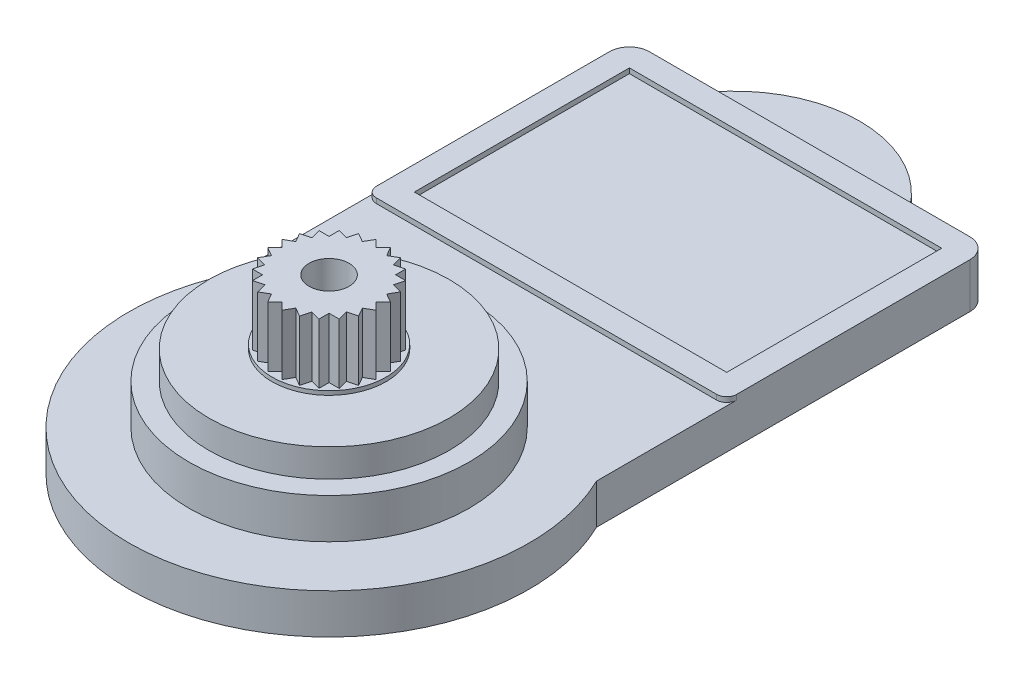
from build123d import *

# Parameters (mm, degrees)
BOSS_EXTRUDE1_DEPTH = 2
BOSS_EXTRUDE2_DEPTH = 0.25
SKETCH3_W           = 15.6
SKETCH3_H           = 10.74
CUT_EXTRUDE1_DEPTH  = 0.25
SKETCH4_R           = 7
BOSS_EXTRUDE3_DEPTH = 2
SKETCH5_R           = 6
BOSS_EXTRUDE4_DEPTH = 1.4
SKETCH6_R           = 2.85
BOSS_EXTRUDE5_DEPTH = 0.2
BOSS_EXTRUDE6_DEPTH = 3
SKETCH10_R          = 1
CUT_EXTRUDE4_DEPTH  = 3


with BuildPart() as part:
    # Sketch1 → Boss-Extrude1 (new body)
    with BuildSketch(Plane(origin=(0, 0, 0), x_dir=(1, 0, 0), z_dir=(0, 1, 0))):
        with BuildLine():
            ThreePointArc((5, 13.05), (0, 15.55), (-5, 13.05))
            Line((-5, 13.05), (-8, 13.05))
            ThreePointArc((-8, 13.05), (-8.70710678, 12.757106782), (-9, 12.050000002))
            Line((-9, 12.050000002), (-9, -6.591101056))
            ThreePointArc((-9, -6.591101056), (0, -20.95), (9, -6.591101056))
            Line((9, -6.591101056), (9, 12.05))
            ThreePointArc((9, 12.05), (8.707106781, 12.757106781), (8, 13.05))
            Line((8, 13.05), (5, 13.05))
        make_face()
    extrude(amount=BOSS_EXTRUDE1_DEPTH)

    # Sketch2 → Boss-Extrude2 (add)
    with BuildSketch(Plane(origin=(0, 2, 0), x_dir=(-1, 0, 0), z_dir=(0, 1, 0))):
        with BuildLine():
            Line((-8.000000002, -13.05), (8, -13.05))
            ThreePointArc((8, -13.05), (8.707106781, -12.757106781), (9, -12.05))
            Line((9, -12.05), (9, -0.41))
            ThreePointArc((9, -0.41), (8.853553391, -0.056446609), (8.5, 0.09))
            Line((8.5, 0.09), (-8.5, 0.09))
            ThreePointArc((-8.5, 0.09), (-8.853553391, -0.056446609), (-9, -0.41))
            Line((-9, -0.41), (-9, -12.05))
            ThreePointArc((-9, -12.05), (-8.707106782, -12.757106781), (-8.000000002, -13.05))
        make_face()
    extrude(amount=BOSS_EXTRUDE2_DEPTH)

    # Sketch3 → Cut-Extrude1 (cut)
    with BuildSketch(Plane(origin=(0, 2.25, 0), x_dir=(-1, 0, 0), z_dir=(0, 1, 0))):
        with Locations((0, -6.48)):
            Rectangle(SKETCH3_W, SKETCH3_H)
    extrude(amount=-CUT_EXTRUDE1_DEPTH, mode=Mode.SUBTRACT)

    # Sketch4 → Boss-Extrude3 (add)
    with BuildSketch(Plane(origin=(0, 2, 0), x_dir=(-1, 0, 0), z_dir=(0, 1, 0))):
        with Locations((0, 10.95)):
            Circle(SKETCH4_R)
    extrude(amount=BOSS_EXTRUDE3_DEPTH)

    # Sketch5 → Boss-Extrude4 (add)
    with BuildSketch(Plane(origin=(0, 4, 0), x_dir=(-1, 0, 0), z_dir=(0, 1, 0))):
        with Locations((0, 10.95)):
            Circle(SKETCH5_R)
    extrude(amount=BOSS_EXTRUDE4_DEPTH)

    # Sketch6 → Boss-Extrude5 (add)
    with BuildSketch(Plane(origin=(0, 5.4, 0), x_dir=(-1, 0, 0), z_dir=(0, 1, 0))):
        with Locations((0, 10.95)):
            Circle(SKETCH6_R)
    extrude(amount=BOSS_EXTRUDE5_DEPTH)

    # Sketch9 → Boss-Extrude6 (add)
    with BuildSketch(Plane(origin=(0, 5.6, 0), x_dir=(-1, 0, 0), z_dir=(0, 1, 0))):
        Polygon((-0.356289813, 8.243710187), (0, 8.6), (0.356289813, 8.243710187), (0.608224756, 8.680074308), (1.044588877, 8.428139365), (1.175, 8.914840301), (1.661700936, 8.784429178), (1.661700936, 9.288299064), (2.165570822, 9.288299064), (2.035159699, 9.775), (2.521860635, 9.905411123), (2.269925692, 10.341775244), (2.706289813, 10.593710187), (2.35, 10.95), (2.706289813, 11.306289813), (2.269925692, 11.558224756), (2.521860635, 11.994588877), (2.035159699, 12.125), (2.165570822, 12.611700936), (1.661700936, 12.611700936), (1.661700936, 13.115570822), (1.175, 12.985159699), (1.044588877, 13.471860635), (0.608224756, 13.219925692), (0.356289813, 13.656289813), (0, 13.3), (-0.356289813, 13.656289813), (-0.608224756, 13.219925692), (-1.044588877, 13.471860635), (-1.175, 12.985159699), (-1.661700936, 13.115570822), (-1.661700936, 12.611700936), (-2.165570822, 12.611700936), (-2.035159699, 12.125), (-2.521860635, 11.994588877), (-2.269925692, 11.558224756), (-2.706289813, 11.306289813), (-2.35, 10.95), (-2.706289813, 10.593710187), (-2.269925692, 10.341775244), (-2.521860635, 9.905411123), (-2.035159699, 9.775), (-2.165570822, 9.288299064), (-1.661700936, 9.288299064), (-1.661700936, 8.784429178), (-1.175, 8.914840301), (-1.044588877, 8.428139365), (-0.608224756, 8.680074308), align=None)
    extrude(amount=BOSS_EXTRUDE6_DEPTH)

    # Sketch10 → Cut-Extrude4 (cut)
    with BuildSketch(Plane(origin=(0, 8.6, 0), x_dir=(-1, 0, 0), z_dir=(0, 1, 0))):
        with Locations((0, 10.95)):
            Circle(SKETCH10_R)
    extrude(amount=-CUT_EXTRUDE4_DEPTH, mode=Mode.SUBTRACT)


solid = part.part
